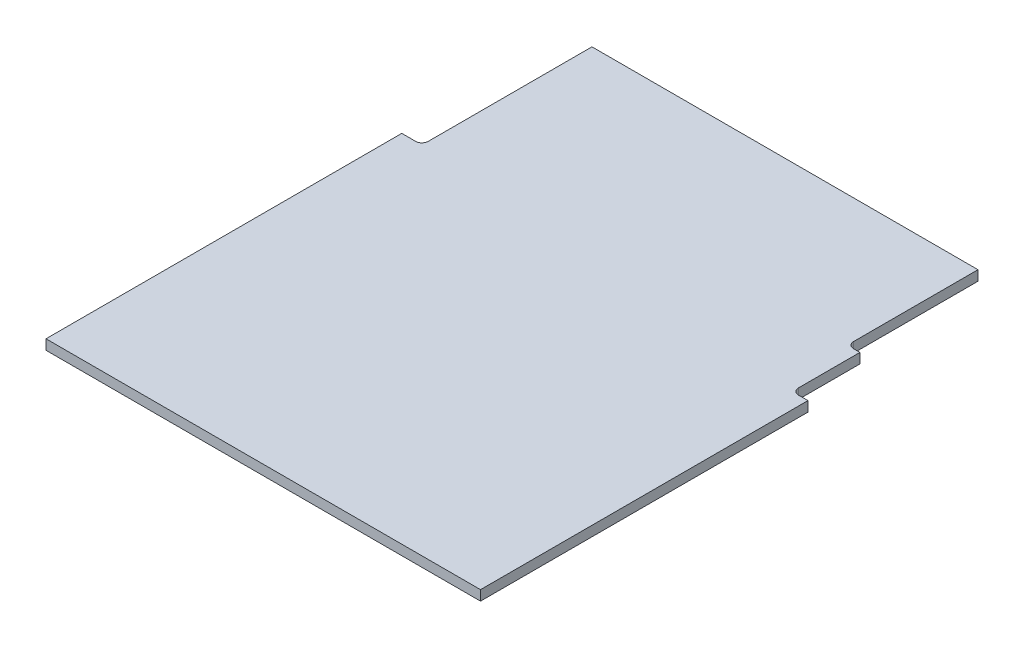
from build123d import *

# Parameters (mm, degrees)
FR4_DEPTH = 1.5875


with BuildPart() as part:
    # Sketch1 → FR4 (new body)
    with BuildSketch(Plane(origin=(0, 0, 0), x_dir=(1, 0, 0), z_dir=(0, 1, 0))):
        with BuildLine():
            Line((34.5, -9), (34.5, 36))
            Line((34.5, 36), (32.940007652, 36))
            ThreePointArc((32.940007652, 36), (32.271894631, 36.313775841), (32, 37))
            Line((32, 37), (32, 46.75))
            Line((32, 46.75), (31, 46.75))
            ThreePointArc((31, 46.75), (30.292893219, 47.042893219), (30, 47.75))
            Line((30, 47.75), (30, 67.5))
            Line((30, 67.5), (-31.3, 67.5))
            Line((-31.3, 67.5), (-31.3, 41.5))
            ThreePointArc((-31.3, 41.5), (-31.564481186, 40.821086647), (-32.218527823, 40.5))
            Line((-32.218527823, 40.5), (-34.5, 40.5))
            Line((-34.5, 40.5), (-34.5, -9))
            Line((-34.5, -9), (-34.5, -16))
            Line((-34.5, -16), (34.5, -16))
            Line((34.5, -16), (34.5, -9))
        make_face()
    extrude(amount=FR4_DEPTH)


solid = part.part
